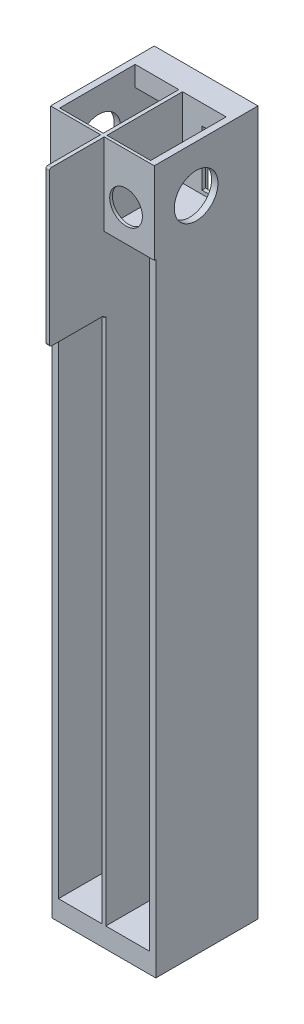
from build123d import *

# Parameters (mm, degrees)
SZKIC1_W                     = 53
SZKIC1_H                     = 374
SZKIC1_W_2                   = 24
SZKIC1_H_2                   = 365
DODANIE_WYCI_GNI_CIE2_DEPTH  = 12
SZKIC2_W                     = 12
SZKIC2_H                     = 3.5
WYTNIJ_WYCI_GNI_CIE1_DEPTH   = 2
SZKIC3_W                     = 53
SZKIC3_H                     = 374
DODANIE_WYCI_GNI_CIE3_DEPTH  = 2
SZKIC4_W                     = 13.3
SZKIC4_H                     = 30.500081729
SZKIC4_W_2                   = 9.4
SZKIC4_H_2                   = 64.96
WYTNIJ_WYCI_GNI_CIE2_DEPTH   = 2
SZKIC5_W                     = 2
SZKIC5_H                     = 374
DODANIE_WYCI_GNI_CIE4_DEPTH  = 43
DODANIE_WYCI_GNI_CIE5_DEPTH  = 41.5
SZKIC7_W                     = 25.5
SZKIC7_H                     = 38.500081729
DODANIE_WYCI_GNI_CIE6_DEPTH  = 1.5
SZKIC9_R                     = 12
WYTNIJ_WYCI_GNI_CIE4_DEPTH   = 1.5
DODANIE_WYCI_GNI_CIE7_DEPTH  = 43
DODANIE_WYCI_GNI_CIE8_DEPTH  = 43
SZKIC12_R                    = 12
WYTNIJ_WYCI_GNI_CIE5_DEPTH   = 1.5
SZKIC13_R                    = 9
WYTNIJ_WYCI_GNI_CIE6_DEPTH   = 1.5
SZKIC14_W                    = 57
SZKIC14_H                    = 374
SZKIC14_R                    = 12
DODANIE_WYCI_GNI_CIE9_DEPTH  = 1
SZKIC15_W                    = 57
SZKIC15_H                    = 374
SZKIC15_R                    = 12
DODANIE_WYCI_GNI_CIE10_DEPTH = 1
SZKIC16_W                    = 55
SZKIC16_H                    = 57
SZKIC16_W_2                  = 24
SZKIC16_H_2                  = 41.5
DODANIE_WYCI_GNI_CIE11_DEPTH = 1
SZKIC17_W                    = 55
SZKIC17_H                    = 57
DODANIE_WYCI_GNI_CIE12_DEPTH = 1
DODANIE_WYCI_GNI_CIE13_DEPTH = 30
SZKIC20_W                    = 55
SZKIC20_H                    = 57
DODANIE_WYCI_GNI_CIE14_DEPTH = 5.5
SZKIC21_W                    = 24
SZKIC21_H                    = 41.5
DODANIE_WYCI_GNI_CIE15_DEPTH = 5.5
SZKIC22_W                    = 57
SZKIC22_H                    = 387
SZKIC22_R                    = 12
DODANIE_WYCI_GNI_CIE16_DEPTH = 1
SZKIC23_W                    = 57
SZKIC23_H                    = 387
SZKIC23_R                    = 12
DODANIE_WYCI_GNI_CIE17_DEPTH = 1
ZAOKR_GLENIE1_R              = 1
ZAOKR_GLENIE2_R              = 1
ZAOKR_GLENIE3_R              = 1
WYTNIJ_WYCI_GNI_CIE7_DEPTH   = 0.85


with BuildPart() as part:
    # Szkic1 → Dodanie-wyciągnięcie2 (new body)
    with BuildSketch(Plane.XY):
        with Locations((-65.426891924, -133.239080048)):
            Rectangle(SZKIC1_W, SZKIC1_H)
        with Locations((-78.426891924, -133.239080048)):
            Rectangle(SZKIC1_W_2, SZKIC1_H_2, mode=Mode.SUBTRACT)
        with Locations((-52.426891924, -133.239080048)):
            Rectangle(SZKIC1_W_2, SZKIC1_H_2, mode=Mode.SUBTRACT)
    extrude(amount=DODANIE_WYCI_GNI_CIE2_DEPTH)

    # Szkic2 → Wytnij-wyciągnięcie1 (cut)
    with BuildSketch(Plane.ZY.offset(66.426891924)):
        with Locations((6, 47.510919952)):
            Rectangle(SZKIC2_W, SZKIC2_H)
    extrude(amount=-WYTNIJ_WYCI_GNI_CIE1_DEPTH, mode=Mode.SUBTRACT)

    # Szkic3 → Dodanie-wyciągnięcie3 (add)
    with BuildSketch(Plane.XY.offset(12)):
        with Locations((-65.426891924, -133.239080048)):
            Rectangle(SZKIC3_W, SZKIC3_H)
    extrude(amount=DODANIE_WYCI_GNI_CIE3_DEPTH)

    # Szkic4 → Wytnij-wyciągnięcie2 (cut)
    with BuildSketch(Plane.XY.offset(14)):
        Polygon((-46.926891924, -11.039080048), (-56.326891924, -11.039080048), (-56.326891924, -35.399080048), (-56.326891924, -40.479080048), (-46.926891924, -40.479080048), (-46.926891924, -35.399080048), align=None)
        with Locations((-47.076891924, 34.010879088)):
            Rectangle(SZKIC4_W, SZKIC4_H)
        with Locations((-83.776891924, 34.010879088)):
            Rectangle(SZKIC4_W, SZKIC4_H)
        Polygon((-74.526891924, -35.399080048), (-74.526891924, -11.039080048), (-83.926891924, -11.039080048), (-83.926891924, -35.399080048), (-83.926891924, -40.479080048), (-74.526891924, -40.479080048), align=None)
        with Locations((-51.626891924, -133.719080048)):
            Rectangle(SZKIC4_W_2, SZKIC4_H_2)
        with Locations((-79.226891924, -133.719080048)):
            Rectangle(SZKIC4_W_2, SZKIC4_H_2)
    extrude(amount=-WYTNIJ_WYCI_GNI_CIE2_DEPTH, mode=Mode.SUBTRACT)

    # Szkic5 → Dodanie-wyciągnięcie4 (add)
    with BuildSketch(Plane.XY.offset(14)):
        with Locations((-65.426891924, -133.239080048)):
            Rectangle(SZKIC5_W, SZKIC5_H)
    extrude(amount=DODANIE_WYCI_GNI_CIE4_DEPTH)

    # Szkic6 → Dodanie-wyciągnięcie5 (add)
    with BuildSketch(Plane.XY.offset(14)):
        Polygon((-64.426891924, 16.760838223), (-40.426891924, 16.760838223), (-40.426891924, 53.760919952), (-38.926891924, 53.760919952), (-38.926891924, 15.260838223), (-64.426891924, 15.260838223), align=None)
        Polygon((-90.426891924, 53.760919952), (-91.926891924, 53.760919952), (-91.926891924, 15.260838223), (-66.426891924, 15.260838223), (-66.426891924, 16.760838223), (-90.426891924, 16.760838223), align=None)
    extrude(amount=DODANIE_WYCI_GNI_CIE5_DEPTH)

    # Szkic7 → Dodanie-wyciągnięcie6 (add)
    with BuildSketch(Plane.XY.offset(55.5)):
        with Locations((-51.676891924, 34.510879088)):
            Rectangle(SZKIC7_W, SZKIC7_H)
        with Locations((-79.176891924, 34.510879088)):
            Rectangle(SZKIC7_W, SZKIC7_H)
    extrude(amount=DODANIE_WYCI_GNI_CIE6_DEPTH)

    # Szkic9 → Wytnij-wyciągnięcie4 (cut)
    with BuildSketch(Plane.ZY.offset(91.926891924)):
        with Locations((34, 34.510879088)):
            Circle(SZKIC9_R)
    extrude(amount=-WYTNIJ_WYCI_GNI_CIE4_DEPTH, mode=Mode.SUBTRACT)

    # Szkic10 → Dodanie-wyciągnięcie7 (add)
    with BuildSketch(Plane.XY.offset(14)):
        Polygon((-91.926891924, 15.260838223), (-91.926891924, -320.239080048), (-66.426891924, -320.239080048), (-66.426891924, -315.739080048), (-90.426891924, -315.739080048), (-90.426891924, 15.260838223), align=None)
    extrude(amount=DODANIE_WYCI_GNI_CIE7_DEPTH)

    # Szkic11 → Dodanie-wyciągnięcie8 (add)
    with BuildSketch(Plane.XY.offset(14)):
        Polygon((-38.926891924, 15.260838223), (-38.926891924, -320.239080048), (-64.426891924, -320.239080048), (-64.426891924, -315.739080048), (-40.426891924, -315.739080048), (-40.426891924, 15.260838223), align=None)
    extrude(amount=DODANIE_WYCI_GNI_CIE8_DEPTH)

    # Szkic12 → Wytnij-wyciągnięcie5 (cut)
    with BuildSketch(Plane(origin=(-38.926891924, 0, 0), x_dir=(0, 0, -1), z_dir=(1, 0, 0))):
        with Locations((-34, 34.510919952)):
            Circle(SZKIC12_R)
    extrude(amount=-WYTNIJ_WYCI_GNI_CIE5_DEPTH, mode=Mode.SUBTRACT)

    # Szkic13 → Wytnij-wyciągnięcie6 (cut)
    with BuildSketch(Plane.XY.offset(57)):
        with Locations((-78.426891924, 32.810879088)):
            Circle(SZKIC13_R)
        with Locations((-52.426891924, 32.810879088)):
            Circle(SZKIC13_R)
    extrude(amount=-WYTNIJ_WYCI_GNI_CIE6_DEPTH, mode=Mode.SUBTRACT)

    # Szkic14 → Dodanie-wyciągnięcie9 (add)
    with BuildSketch(Plane(origin=(-38.926891924, 0, 0), x_dir=(0, 0, -1), z_dir=(1, 0, 0))):
        with Locations((-28.5, -133.239080048)):
            Rectangle(SZKIC14_W, SZKIC14_H)
        with Locations((-34, 34.510919952)):
            Circle(SZKIC14_R, mode=Mode.SUBTRACT)
    extrude(amount=DODANIE_WYCI_GNI_CIE9_DEPTH)

    # Szkic15 → Dodanie-wyciągnięcie10 (add)
    with BuildSketch(Plane.ZY.offset(91.926891924)):
        with Locations((28.5, -133.239080048)):
            Rectangle(SZKIC15_W, SZKIC15_H)
        with Locations((34, 34.510879088)):
            Circle(SZKIC15_R, mode=Mode.SUBTRACT)
    extrude(amount=DODANIE_WYCI_GNI_CIE10_DEPTH)

    # Szkic16 → Dodanie-wyciągnięcie11 (add)
    with BuildSketch(Plane(origin=(0, 53.760919952, 0), x_dir=(1, 0, 0), z_dir=(0, 1, 0))):
        with Locations((-65.426891924, -28.5)):
            Rectangle(SZKIC16_W, SZKIC16_H)
        with Locations((-52.426891924, -34.75)):
            Rectangle(SZKIC16_W_2, SZKIC16_H_2, mode=Mode.SUBTRACT)
        with Locations((-78.426891924, -34.75)):
            Rectangle(SZKIC16_W_2, SZKIC16_H_2, mode=Mode.SUBTRACT)
    extrude(amount=DODANIE_WYCI_GNI_CIE11_DEPTH)

    # Szkic17 → Dodanie-wyciągnięcie12 (add)
    with BuildSketch(Plane.XZ.offset(320.239080048)):
        with Locations((-65.426891924, 28.5)):
            Rectangle(SZKIC17_W, SZKIC17_H)
    extrude(amount=DODANIE_WYCI_GNI_CIE12_DEPTH)

    # Szkic18 → Dodanie-wyciągnięcie13 (add)
    with BuildSketch(Plane.XY.offset(57)):
        Polygon((-64.426891924, 15.260838223), (-64.426891924, 54.760919952), (-66.426891924, 54.760919952), (-66.426891924, 15.260838223), (-66.426891924, -4.739161777), (-66.426891924, -24.739161777), (-64.426891924, -24.739161777), (-64.426891924, -4.739161777), align=None)
    extrude(amount=DODANIE_WYCI_GNI_CIE13_DEPTH)

    # Szkic20 → Dodanie-wyciągnięcie14 (add)
    with BuildSketch(Plane.XZ.offset(321.239080048)):
        with Locations((-65.426891924, 28.5)):
            Rectangle(SZKIC20_W, SZKIC20_H)
    extrude(amount=DODANIE_WYCI_GNI_CIE14_DEPTH)

    # Szkic21 → Dodanie-wyciągnięcie15 (add)
    with BuildSketch(Plane(origin=(0, 54.760919952, 0), x_dir=(1, 0, 0), z_dir=(0, 1, 0))):
        Polygon((-64.426891924, -87), (-66.426891924, -87), (-66.426891924, -57), (-92.926891924, -57), (-92.926891924, 0), (-37.926891924, 0), (-37.926891924, -57), (-64.426891924, -57), align=None)
        with Locations((-52.426891924, -34.75)):
            Rectangle(SZKIC21_W, SZKIC21_H, mode=Mode.SUBTRACT)
        with Locations((-78.426891924, -34.75)):
            Rectangle(SZKIC21_W, SZKIC21_H, mode=Mode.SUBTRACT)
    extrude(amount=DODANIE_WYCI_GNI_CIE15_DEPTH)

    # Szkic22 → Dodanie-wyciągnięcie16 (add)
    with BuildSketch(Plane(origin=(-37.926891924, 0, 0), x_dir=(0, 0, -1), z_dir=(1, 0, 0))):
        with Locations((-28.5, -133.239080048)):
            Rectangle(SZKIC22_W, SZKIC22_H)
        with Locations((-34, 34.510919952)):
            Circle(SZKIC22_R, mode=Mode.SUBTRACT)
    extrude(amount=DODANIE_WYCI_GNI_CIE16_DEPTH)

    # Szkic23 → Dodanie-wyciągnięcie17 (add)
    with BuildSketch(Plane.ZY.offset(92.926891924)):
        with Locations((28.5, -133.239080048)):
            Rectangle(SZKIC23_W, SZKIC23_H)
        with Locations((34, 34.510879088)):
            Circle(SZKIC23_R, mode=Mode.SUBTRACT)
    extrude(amount=DODANIE_WYCI_GNI_CIE17_DEPTH)

    # Zaokrąglenie1
    zaokr_glenie1_edges = [part.edges().sort_by_distance(p)[0] for p in [
        (-65.426891924, -24.739161777, 87),
    ]]
    fillet(zaokr_glenie1_edges, radius=ZAOKR_GLENIE1_R)

    # Zaokrąglenie2
    zaokr_glenie2_edges = [part.edges().sort_by_distance(p)[0] for p in [
        (-65.426891924, -24.739161777, 57),
    ]]
    fillet(zaokr_glenie2_edges, radius=ZAOKR_GLENIE2_R)

    # Zaokrąglenie3
    zaokr_glenie3_edges = [part.edges().sort_by_distance(p)[0] for p in [
        (-65.426891924, 60.260919952, 87),
    ]]
    fillet(zaokr_glenie3_edges, radius=ZAOKR_GLENIE3_R)

    # Szkic24 → Wytnij-wyciągnięcie7 (cut)
    with BuildSketch(Plane.XY.offset(57)):
        Polygon((-64.426891924, 15.260838223), (-64.426891924, -25.739161777), (-66.426891924, -25.739161777), (-66.426891924, 15.260838223), (-93.926891924, 15.260838223), (-93.926891924, -326.739080048), (-36.926891924, -326.739080048), (-36.926891924, 15.260838223), align=None)
    extrude(amount=-WYTNIJ_WYCI_GNI_CIE7_DEPTH, mode=Mode.SUBTRACT)


solid = part.part
